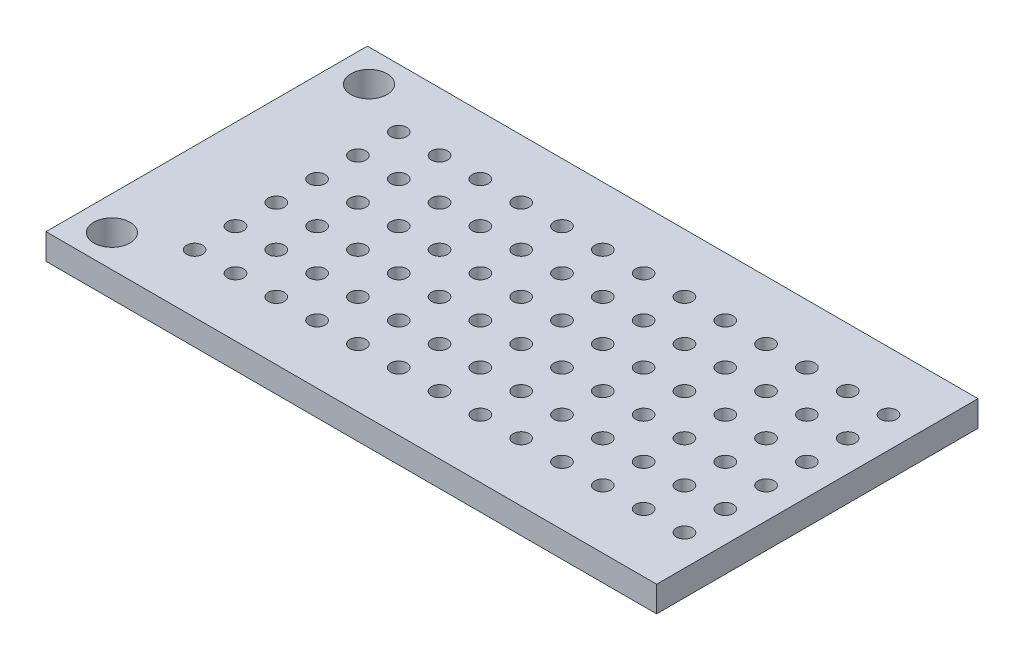
from build123d import *

# Parameters (mm, degrees)
SKETCH1_W           = 38
SKETCH1_H           = 20
BOSS_EXTRUDE1_DEPTH = 1.6
SKETCH2_R           = 1.125
CUT_EXTRUDE1_DEPTH  = 2.6
SKETCH3_R           = 0.5
CUT_EXTRUDE2_DEPTH  = 2.6


with BuildPart() as part:
    # Sketch1 → Boss-Extrude1 (new body)
    with BuildSketch(Plane(origin=(0, 0, 0), x_dir=(1, 0, 0), z_dir=(0, 1, 0))):
        with Locations((19, 10)):
            Rectangle(SKETCH1_W, SKETCH1_H)
    extrude(amount=BOSS_EXTRUDE1_DEPTH)

    # Sketch2 → Cut-Extrude1 (cut, through all)
    with BuildSketch(Plane(origin=(0, 1.6, 0), x_dir=(1, 0, 0), z_dir=(0, 1, 0))):
        with Locations((2.1, 18)):
            Circle(SKETCH2_R)
        with Locations((2.1, 2)):
            Circle(SKETCH2_R)
    extrude(amount=-CUT_EXTRUDE1_DEPTH, mode=Mode.SUBTRACT)

    # Sketch3 → Cut-Extrude2 (cut, through all)
    with BuildSketch(Plane(origin=(0, 1.6, 0), x_dir=(1, 0, 0), z_dir=(0, 1, 0))):
        with Locations((5.6, 16.35)):
            Circle(SKETCH3_R)
        with Locations((8.14, 16.35)):
            Circle(SKETCH3_R)
        with Locations((10.68, 16.35)):
            Circle(SKETCH3_R)
        with Locations((13.22, 16.35)):
            Circle(SKETCH3_R)
        with Locations((15.76, 16.35)):
            Circle(SKETCH3_R)
        with Locations((18.3, 16.35)):
            Circle(SKETCH3_R)
        with Locations((20.84, 16.35)):
            Circle(SKETCH3_R)
        with Locations((23.38, 16.35)):
            Circle(SKETCH3_R)
        with Locations((25.92, 16.35)):
            Circle(SKETCH3_R)
        with Locations((28.46, 16.35)):
            Circle(SKETCH3_R)
        with Locations((31, 16.35)):
            Circle(SKETCH3_R)
        with Locations((33.54, 16.35)):
            Circle(SKETCH3_R)
        with Locations((36.08, 16.35)):
            Circle(SKETCH3_R)
        with Locations((8.14, 13.81)):
            Circle(SKETCH3_R)
        with Locations((10.68, 13.81)):
            Circle(SKETCH3_R)
        with Locations((13.22, 13.81)):
            Circle(SKETCH3_R)
        with Locations((15.76, 13.81)):
            Circle(SKETCH3_R)
        with Locations((18.3, 13.81)):
            Circle(SKETCH3_R)
        with Locations((20.84, 13.81)):
            Circle(SKETCH3_R)
        with Locations((23.38, 13.81)):
            Circle(SKETCH3_R)
        with Locations((25.92, 13.81)):
            Circle(SKETCH3_R)
        with Locations((28.46, 13.81)):
            Circle(SKETCH3_R)
        with Locations((31, 13.81)):
            Circle(SKETCH3_R)
        with Locations((33.54, 13.81)):
            Circle(SKETCH3_R)
        with Locations((36.08, 13.81)):
            Circle(SKETCH3_R)
        with Locations((8.14, 11.27)):
            Circle(SKETCH3_R)
        with Locations((10.68, 11.27)):
            Circle(SKETCH3_R)
        with Locations((13.22, 11.27)):
            Circle(SKETCH3_R)
        with Locations((15.76, 11.27)):
            Circle(SKETCH3_R)
        with Locations((18.3, 11.27)):
            Circle(SKETCH3_R)
        with Locations((20.84, 11.27)):
            Circle(SKETCH3_R)
        with Locations((23.38, 11.27)):
            Circle(SKETCH3_R)
        with Locations((25.92, 11.27)):
            Circle(SKETCH3_R)
        with Locations((28.46, 11.27)):
            Circle(SKETCH3_R)
        with Locations((31, 11.27)):
            Circle(SKETCH3_R)
        with Locations((33.54, 11.27)):
            Circle(SKETCH3_R)
        with Locations((36.08, 11.27)):
            Circle(SKETCH3_R)
        with Locations((8.14, 8.73)):
            Circle(SKETCH3_R)
        with Locations((10.68, 8.73)):
            Circle(SKETCH3_R)
        with Locations((13.22, 8.73)):
            Circle(SKETCH3_R)
        with Locations((15.76, 8.73)):
            Circle(SKETCH3_R)
        with Locations((18.3, 8.73)):
            Circle(SKETCH3_R)
        with Locations((20.84, 8.73)):
            Circle(SKETCH3_R)
        with Locations((23.38, 8.73)):
            Circle(SKETCH3_R)
        with Locations((25.92, 8.73)):
            Circle(SKETCH3_R)
        with Locations((28.46, 8.73)):
            Circle(SKETCH3_R)
        with Locations((31, 8.73)):
            Circle(SKETCH3_R)
        with Locations((33.54, 8.73)):
            Circle(SKETCH3_R)
        with Locations((36.08, 8.73)):
            Circle(SKETCH3_R)
        with Locations((8.14, 6.19)):
            Circle(SKETCH3_R)
        with Locations((10.68, 6.19)):
            Circle(SKETCH3_R)
        with Locations((13.22, 6.19)):
            Circle(SKETCH3_R)
        with Locations((15.76, 6.19)):
            Circle(SKETCH3_R)
        with Locations((18.3, 6.19)):
            Circle(SKETCH3_R)
        with Locations((20.84, 6.19)):
            Circle(SKETCH3_R)
        with Locations((23.38, 6.19)):
            Circle(SKETCH3_R)
        with Locations((25.92, 6.19)):
            Circle(SKETCH3_R)
        with Locations((28.46, 6.19)):
            Circle(SKETCH3_R)
        with Locations((31, 6.19)):
            Circle(SKETCH3_R)
        with Locations((33.54, 6.19)):
            Circle(SKETCH3_R)
        with Locations((36.08, 6.19)):
            Circle(SKETCH3_R)
        with Locations((8.14, 3.65)):
            Circle(SKETCH3_R)
        with Locations((10.68, 3.65)):
            Circle(SKETCH3_R)
        with Locations((13.22, 3.65)):
            Circle(SKETCH3_R)
        with Locations((15.76, 3.65)):
            Circle(SKETCH3_R)
        with Locations((18.3, 3.65)):
            Circle(SKETCH3_R)
        with Locations((20.84, 3.65)):
            Circle(SKETCH3_R)
        with Locations((23.38, 3.65)):
            Circle(SKETCH3_R)
        with Locations((25.92, 3.65)):
            Circle(SKETCH3_R)
        with Locations((28.46, 3.65)):
            Circle(SKETCH3_R)
        with Locations((31, 3.65)):
            Circle(SKETCH3_R)
        with Locations((33.54, 3.65)):
            Circle(SKETCH3_R)
        with Locations((36.08, 3.65)):
            Circle(SKETCH3_R)
        with Locations((5.6, 13.81)):
            Circle(SKETCH3_R)
        with Locations((5.6, 11.27)):
            Circle(SKETCH3_R)
        with Locations((5.6, 8.73)):
            Circle(SKETCH3_R)
        with Locations((5.6, 6.19)):
            Circle(SKETCH3_R)
        with Locations((5.6, 3.65)):
            Circle(SKETCH3_R)
    extrude(amount=-CUT_EXTRUDE2_DEPTH, mode=Mode.SUBTRACT)


solid = part.part
